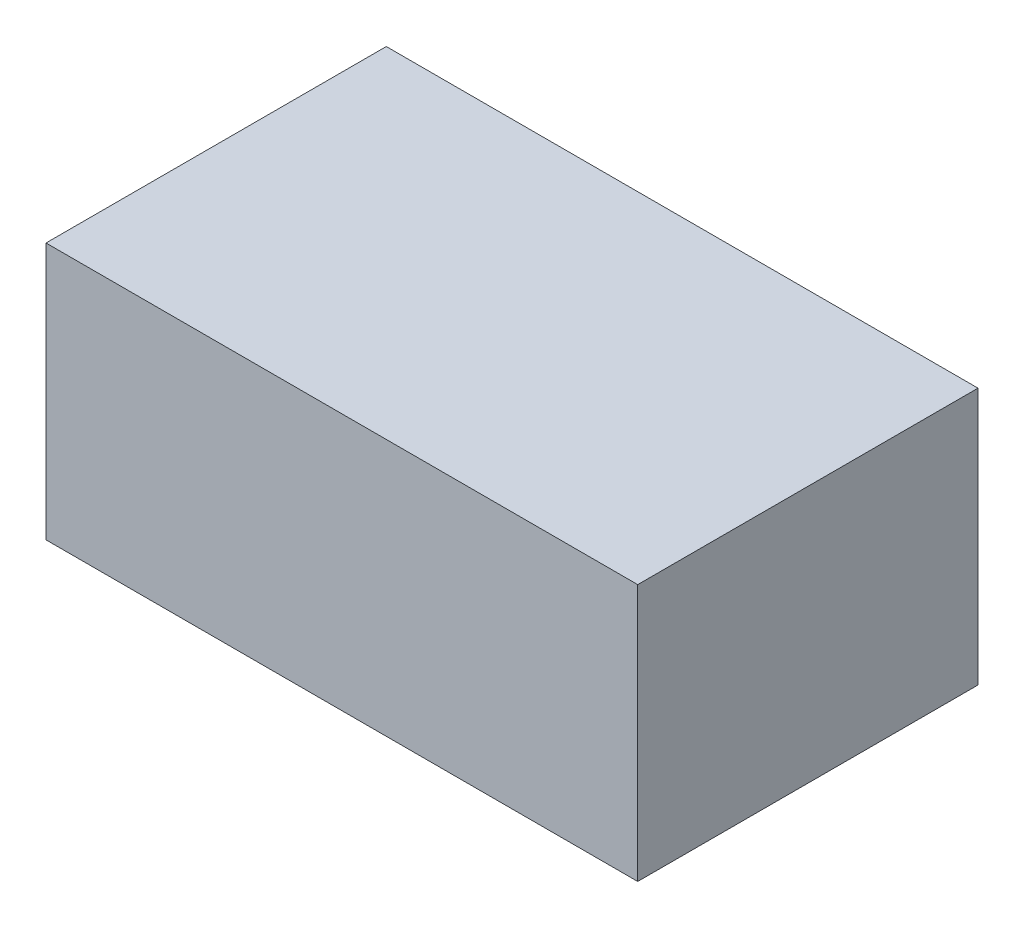
from build123d import *

# Parameters (mm, degrees)
SKETCH1_W           = 39.751
SKETCH1_H           = 22.86
BOSS_EXTRUDE1_DEPTH = 8.636


with BuildPart() as part:
    # Sketch1 → Boss-Extrude1 (new body, symmetric)
    with BuildSketch(Plane(origin=(0, 0, 0), x_dir=(1, 0, 0), z_dir=(0, 1, 0))):
        Rectangle(SKETCH1_W, SKETCH1_H)
    extrude(amount=BOSS_EXTRUDE1_DEPTH, both=True)


solid = part.part
